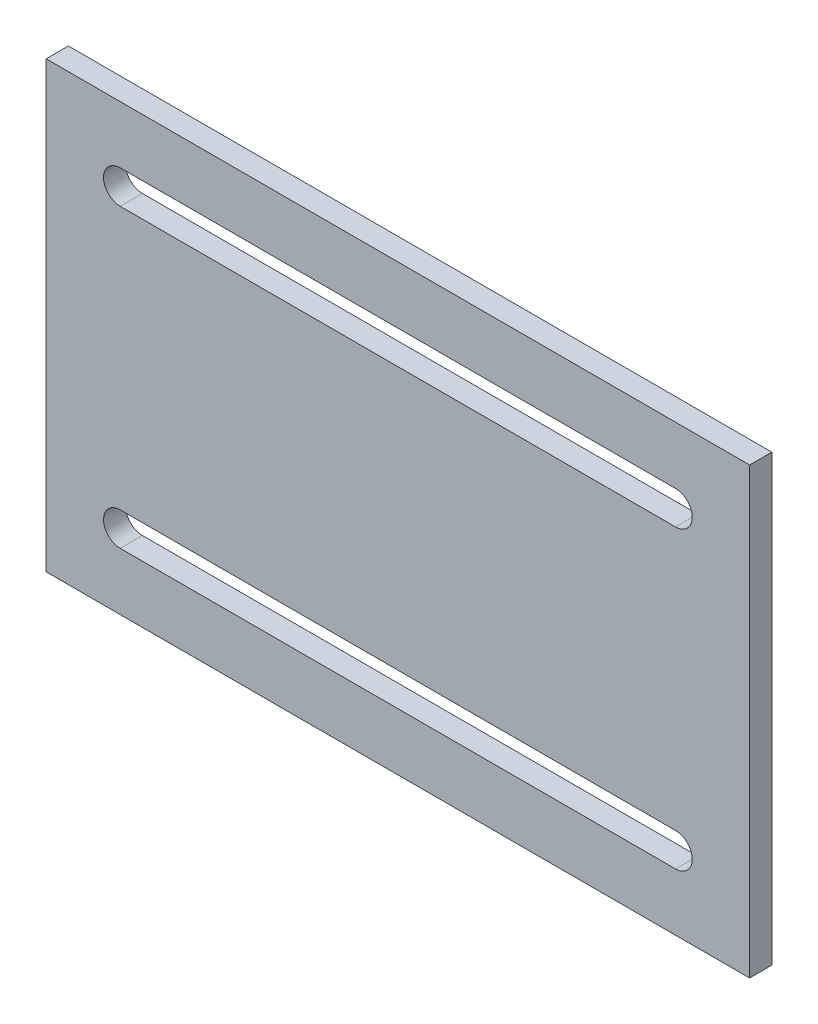
from build123d import *

# Parameters (mm, degrees)
SKETCH1_W           = 380
SKETCH1_H           = 240
BOSS_EXTRUDE1_DEPTH = 12


with BuildPart() as part:
    # Sketch1 → Boss-Extrude1 (new body)
    with BuildSketch(Plane.XY):
        Rectangle(SKETCH1_W, SKETCH1_H)
        with BuildLine():
            Line((-150, 89), (150, 89))
            ThreePointArc((150, 89), (159, 80), (150, 71))
            Line((150, 71), (-150, 71))
            ThreePointArc((-150, 71), (-159, 80), (-150, 89))
        make_face(mode=Mode.SUBTRACT)
        with BuildLine():
            Line((-150, -89), (150, -89))
            ThreePointArc((150, -89), (159, -80), (150, -71))
            Line((150, -71), (-150, -71))
            ThreePointArc((-150, -71), (-159, -80), (-150, -89))
        make_face(mode=Mode.SUBTRACT)
    extrude(amount=BOSS_EXTRUDE1_DEPTH)


solid = part.part
